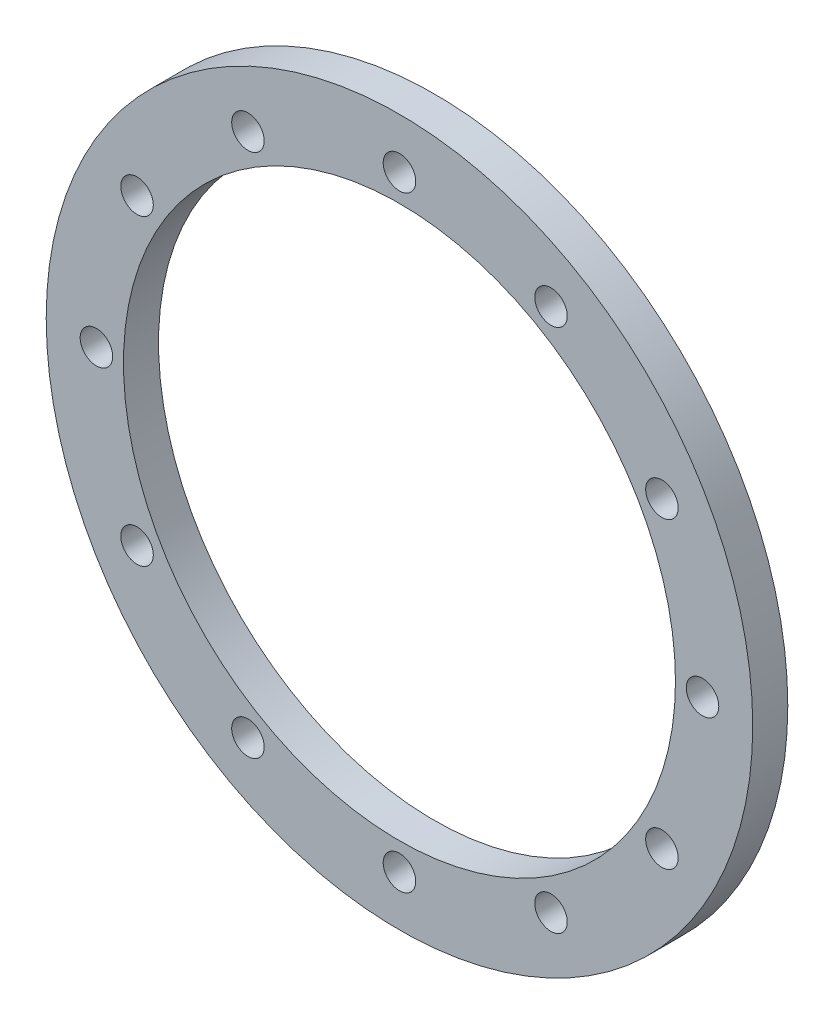
from build123d import *

# Parameters (mm, degrees)
SKETCH1_R           = 32
SKETCH1_R_2         = 25
SKETCH1_R_3         = 1.4732
BOSS_EXTRUDE1_DEPTH = 3.175


with BuildPart() as part:
    # Sketch1 → Boss-Extrude1 (new body)
    with BuildSketch(Plane.XY.offset(0.2)):
        with Locations((-17.5, -28.25)):
            Circle(SKETCH1_R)
        with Locations((-17.5, -28.25)):
            Circle(SKETCH1_R_2, mode=Mode.SUBTRACT)
        with Locations((-17.5, -55.7)):
            Circle(SKETCH1_R_3, mode=Mode.SUBTRACT)
        with Locations((-31.225, -52.022397334)):
            Circle(SKETCH1_R_3, mode=Mode.SUBTRACT)
        with Locations((-41.272397334, -41.975)):
            Circle(SKETCH1_R_3, mode=Mode.SUBTRACT)
        with Locations((-44.95, -28.25)):
            Circle(SKETCH1_R_3, mode=Mode.SUBTRACT)
        with Locations((-41.272397334, -14.525)):
            Circle(SKETCH1_R_3, mode=Mode.SUBTRACT)
        with Locations((-31.225, -4.477602666)):
            Circle(SKETCH1_R_3, mode=Mode.SUBTRACT)
        with Locations((-17.5, -0.8)):
            Circle(SKETCH1_R_3, mode=Mode.SUBTRACT)
        with Locations((-3.775, -4.477602666)):
            Circle(SKETCH1_R_3, mode=Mode.SUBTRACT)
        with Locations((6.272397334, -14.525)):
            Circle(SKETCH1_R_3, mode=Mode.SUBTRACT)
        with Locations((9.95, -28.25)):
            Circle(SKETCH1_R_3, mode=Mode.SUBTRACT)
        with Locations((6.272397334, -41.975)):
            Circle(SKETCH1_R_3, mode=Mode.SUBTRACT)
        with Locations((-3.775, -52.022397334)):
            Circle(SKETCH1_R_3, mode=Mode.SUBTRACT)
    extrude(amount=BOSS_EXTRUDE1_DEPTH)


solid = part.part
